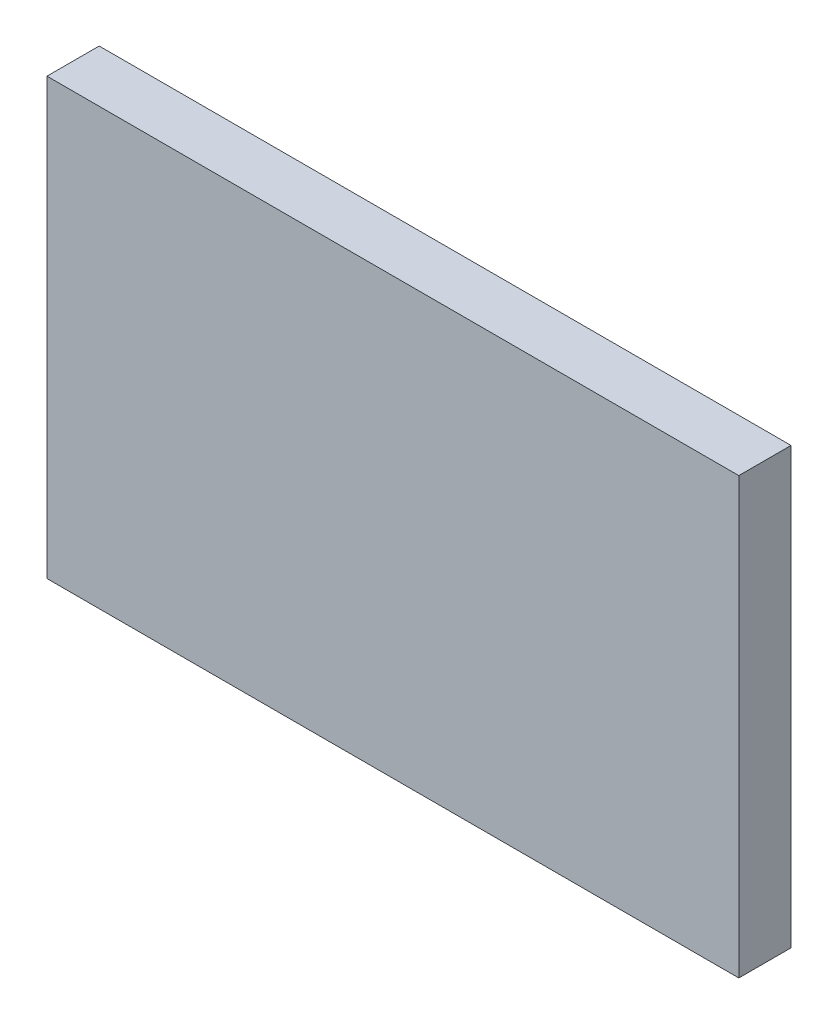
from build123d import *

# Parameters (mm, degrees)
CROQUIS1_W              = 159
CROQUIS1_H              = 100
SALIENTE_EXTRUIR1_DEPTH = 12


with BuildPart() as part:
    # Croquis1 → Saliente-Extruir1 (new body)
    with BuildSketch(Plane.XY):
        with Locations((79.5, 50)):
            Rectangle(CROQUIS1_W, CROQUIS1_H)
    extrude(amount=SALIENTE_EXTRUIR1_DEPTH)


solid = part.part
